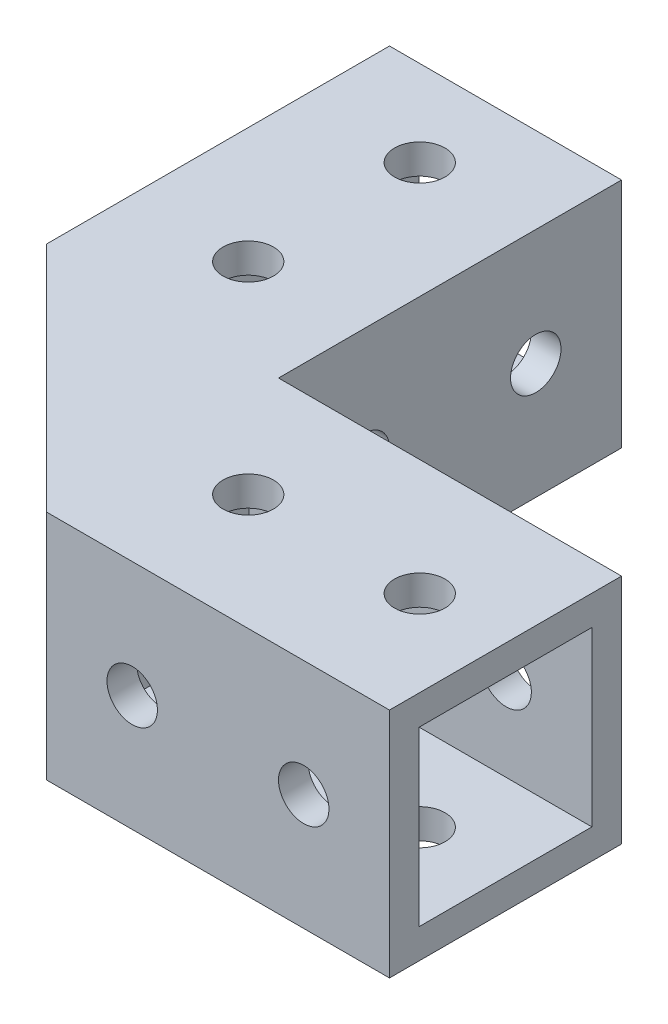
from build123d import *

# Parameters (mm, degrees)
SKETCH1_W           = 34
SKETCH1_H           = 23
SKETCH1_R           = 2.5
BOSS_EXTRUDE1_DEPTH = 23
SKETCH6_OUTSIDE_W   = 45.41
SKETCH6_OUTSIDE_H   = 34.41
SKETCH6_OUTSIDE_W_2 = 34
SKETCH6_OUTSIDE_H_2 = 23
SKETCH6_OUTSIDE_R   = 2.5
CUT_EXTRUDE10_DEPTH = 24
SKETCH7_OUTSIDE_W   = 34.41
SKETCH7_OUTSIDE_H   = 34.41
SKETCH7_OUTSIDE_W_2 = 23
SKETCH7_OUTSIDE_H_2 = 23
SKETCH7_OUTSIDE_W_3 = 17.12
SKETCH7_OUTSIDE_H_3 = 17.12
CUT_EXTRUDE11_DEPTH = 34
BOSS_EXTRUDE2_DEPTH = 23
SKETCH13_R          = 2.5
BOSS_EXTRUDE3_DEPTH = 4


with BuildPart() as part:
    # sketch1 → Boss-Extrude1 (new body)
    with BuildSketch(Plane(origin=(0, 0, 0), x_dir=(1, 0, 0), z_dir=(0, 1, 0))):
        with Locations((17, -11.5)):
            Rectangle(SKETCH1_W, SKETCH1_H)
        with Locations((8.5, -11.5)):
            Circle(SKETCH1_R, mode=Mode.SUBTRACT)
        with Locations((25.5, -11.5)):
            Circle(SKETCH1_R, mode=Mode.SUBTRACT)
    extrude(amount=BOSS_EXTRUDE1_DEPTH)

    # Sketch6 outside → Cut-Extrude10 (cut, through all)
    with BuildSketch(Plane(origin=(0, 0, 0), x_dir=(-1, 0, 0), z_dir=(0, 0, -1))):
        with Locations((-17, 11.5)):
            Rectangle(SKETCH6_OUTSIDE_W, SKETCH6_OUTSIDE_H)
        with Locations((-17, 11.5)):
            Rectangle(SKETCH6_OUTSIDE_W_2, SKETCH6_OUTSIDE_H_2, mode=Mode.SUBTRACT)
        with Locations((-25.5, 11.5)):
            Circle(SKETCH6_OUTSIDE_R)
        with Locations((-8.5, 11.5)):
            Circle(SKETCH6_OUTSIDE_R)
    extrude(amount=-CUT_EXTRUDE10_DEPTH, mode=Mode.SUBTRACT)

    # Sketch7 outside → Cut-Extrude11 (cut)
    with BuildSketch(Plane(origin=(34, 0, 0), x_dir=(0, 0, -1), z_dir=(1, 0, 0))):
        with Locations((-11.5, 11.5)):
            Rectangle(SKETCH7_OUTSIDE_W, SKETCH7_OUTSIDE_H)
        with Locations((-11.5, 11.5)):
            Rectangle(SKETCH7_OUTSIDE_W_2, SKETCH7_OUTSIDE_H_2, mode=Mode.SUBTRACT)
        with Locations((-11.5, 11.5)):
            Rectangle(SKETCH7_OUTSIDE_W_3, SKETCH7_OUTSIDE_H_3)
    extrude(amount=-CUT_EXTRUDE11_DEPTH, mode=Mode.SUBTRACT)


with BuildPart() as body_2:
    # Mirror6: mirrored copy
    add(part.part.mirror(Plane(origin=(0, 0, 0), x_dir=(-0.707106781, 0, 0.707106781), z_dir=(-0.707106781, 0, -0.707106781))))


with BuildPart() as part_1:
    add(part.part)

    add(body_2.part)  # Boss-Extrude2 merges body 2
    # Sketch11 → Boss-Extrude2 (add)
    with BuildSketch(Plane(origin=(0, 0, 0), x_dir=(1, 0, 0), z_dir=(0, 1, 0))):
        Polygon((-23, 0), (0, -23), (0, 0), align=None)
    extrude(amount=BOSS_EXTRUDE2_DEPTH)

    # Sketch13 → Boss-Extrude3 (add)
    with BuildSketch(Plane(origin=(0, 0, 0), x_dir=(1, 0, 0), z_dir=(0, 1, 0))):
        Polygon((8.706365938, 8.706365938), (0, 17), (0, 0), (17, 0), align=None)
        with Locations((5.170832032, 5.170832032)):
            Circle(SKETCH13_R, mode=Mode.SUBTRACT)
    extrude(amount=BOSS_EXTRUDE3_DEPTH)


solid = part_1.part
